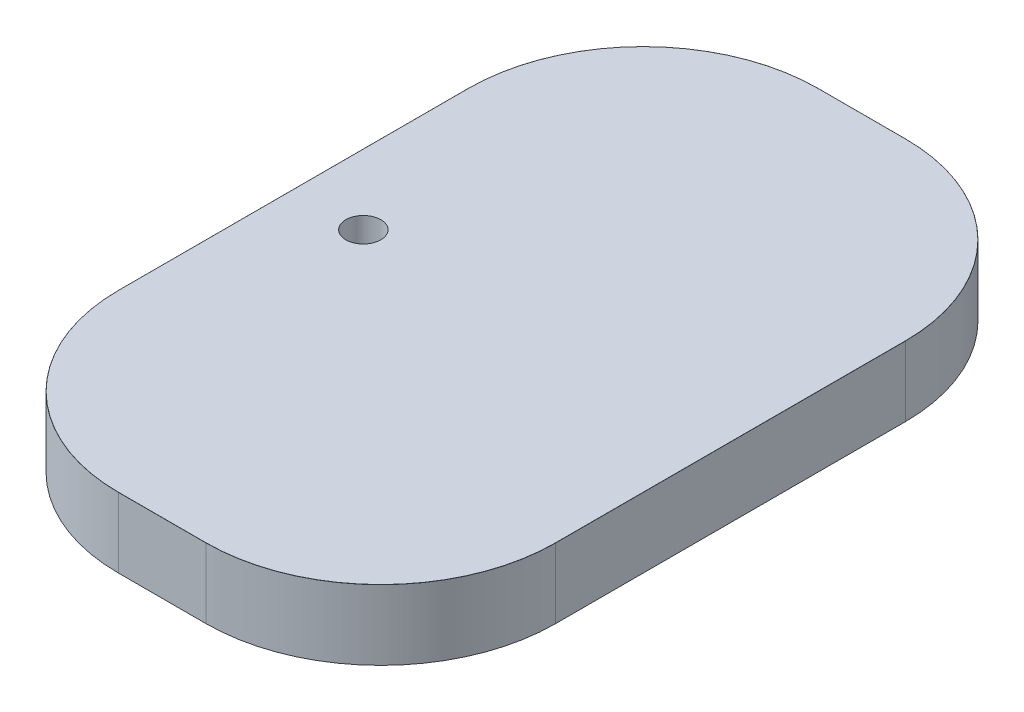
from build123d import *

# Parameters (mm, degrees)
SALIENTE_EXTRUIR1_DEPTH = 8
REDONDEO1_R             = 0.01
CROQUIS3_R              = 2
CORTAR_EXTRUIR1_DEPTH   = 6
CROQUIS4_R              = 1.25
CORTAR_EXTRUIR2_DEPTH   = 10


with BuildPart() as part:
    # Croquis2 → Saliente-Extruir1 (new body)
    with BuildSketch(Plane(origin=(0, 0, 0), x_dir=(1, 0, 0), z_dir=(0, 1, 0))):
        with BuildLine():
            Line((-5, 40), (5, 40))
            ThreePointArc((5, 40), (19.142135624, 34.142135624), (25, 20))
            Line((25, 20), (25, -20))
            ThreePointArc((25, -20), (19.142135624, -34.142135624), (5, -40))
            Line((5, -40), (-5, -40))
            ThreePointArc((-5, -40), (-19.142135624, -34.142135624), (-25, -20))
            Line((-25, -20), (-25, 20))
            ThreePointArc((-25, 20), (-19.142135624, 34.142135624), (-5, 40))
        make_face()
    extrude(amount=SALIENTE_EXTRUIR1_DEPTH)

    # Redondeo1
    redondeo1_edges = [part.edges().sort_by_distance(p)[0] for p in [
        (-19.142135624, 8, 34.142135624),
        (0, 8, 40),
        (19.142135624, 8, 34.142135624),
        (25, 8, 0),
        (19.142135624, 8, -34.142135624),
        (0, 8, -40),
        (-19.142135624, 8, -34.142135624),
        (-25, 8, 0),
    ]]
    fillet(redondeo1_edges, radius=REDONDEO1_R)

    # Croquis3 → Cortar-Extruir1 (cut)
    with BuildSketch(Plane(origin=(0, 8, 0), x_dir=(1, 0, 0), z_dir=(0, 1, 0))):
        with Locations((-17, 0)):
            Circle(CROQUIS3_R)
    extrude(amount=-CORTAR_EXTRUIR1_DEPTH, mode=Mode.SUBTRACT)

    # Croquis4 → Cortar-Extruir2 (cut)
    with BuildSketch(Plane(origin=(0, 8, 0), x_dir=(1, 0, 0), z_dir=(0, 1, 0))):
        with Locations((-17, 0)):
            Circle(CROQUIS4_R)
    extrude(amount=-CORTAR_EXTRUIR2_DEPTH, mode=Mode.SUBTRACT)


solid = part.part
